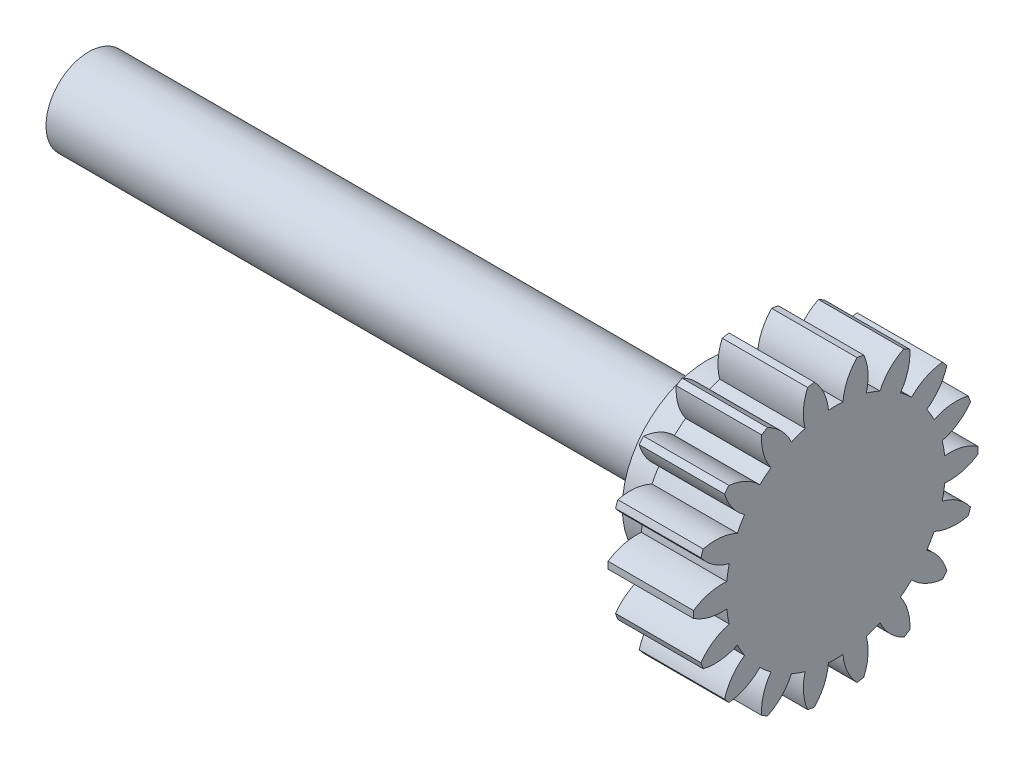
from build123d import *

# Parameters (mm, degrees)
BASPROSKE_W         = 3.175
BASPROSKE_H         = 5.291666667
TOOTHCUT_DEPTH      = 9.129212583
TEETHCUTS_COUNT     = 18
TEETHCUTS_ANGLE     = 340
SKETCH2_3_R         = 1.5875
BOSS_EXTRUDE1_DEPTH = 24.60625
SKETCH3_R           = 3.175
BOSS_EXTRUDE2_DEPTH = 1.5875


with BuildPart() as part:
    # BasProSke → Base-Revolve (revolve)
    with BuildSketch(Plane(origin=(0, 0, 0), x_dir=(1, 0, 0), z_dir=(0, 1, 0))):
        with Locations((1.5875, 2.645833334)):
            Rectangle(BASPROSKE_W, BASPROSKE_H)
    revolve(axis=Axis((-10, 0, 0), (1, 0, 0)))

    # TooCutSke → ToothCut (cut, through all)
    with BuildSketch(Plane(origin=(0, 0, 0), x_dir=(0, 0, -1), z_dir=(1, 0, 0))):
        with BuildLine():
            ThreePointArc((0.270003318, 4.067748898), (0, 4.0767), (-0.270003318, 4.067748898))
            ThreePointArc((-0.270003318, 4.067748898), (-0.437425956, 4.709129954), (-0.814487039, 5.254313352))
            ThreePointArc((-0.814487039, 5.254313352), (0, 5.317066667), (0.814487039, 5.254313352))
            ThreePointArc((0.814487039, 5.254313352), (0.437425956, 4.709129954), (0.270003318, 4.067748898))
        make_face()
    toothcut = extrude(amount=TOOTHCUT_DEPTH, mode=Mode.SUBTRACT)

    # TeethCuts: ToothCut ×18 about axis
    teethcuts_axis = Axis((-10, 0, 0), (1, 0, 0))
    for i in range(1, TEETHCUTS_COUNT):
        add(toothcut.rotate(teethcuts_axis, i * TEETHCUTS_ANGLE / (TEETHCUTS_COUNT - 1)), mode=Mode.SUBTRACT)

    # Sketch2_3 → Boss-Extrude1 (add)
    with BuildSketch(Plane.ZY):
        Circle(SKETCH2_3_R)
    extrude(amount=BOSS_EXTRUDE1_DEPTH)

    # Sketch3 → Boss-Extrude2 (add)
    with BuildSketch(Plane.ZY):
        Circle(SKETCH3_R)
    extrude(amount=BOSS_EXTRUDE2_DEPTH)


solid = part.part
